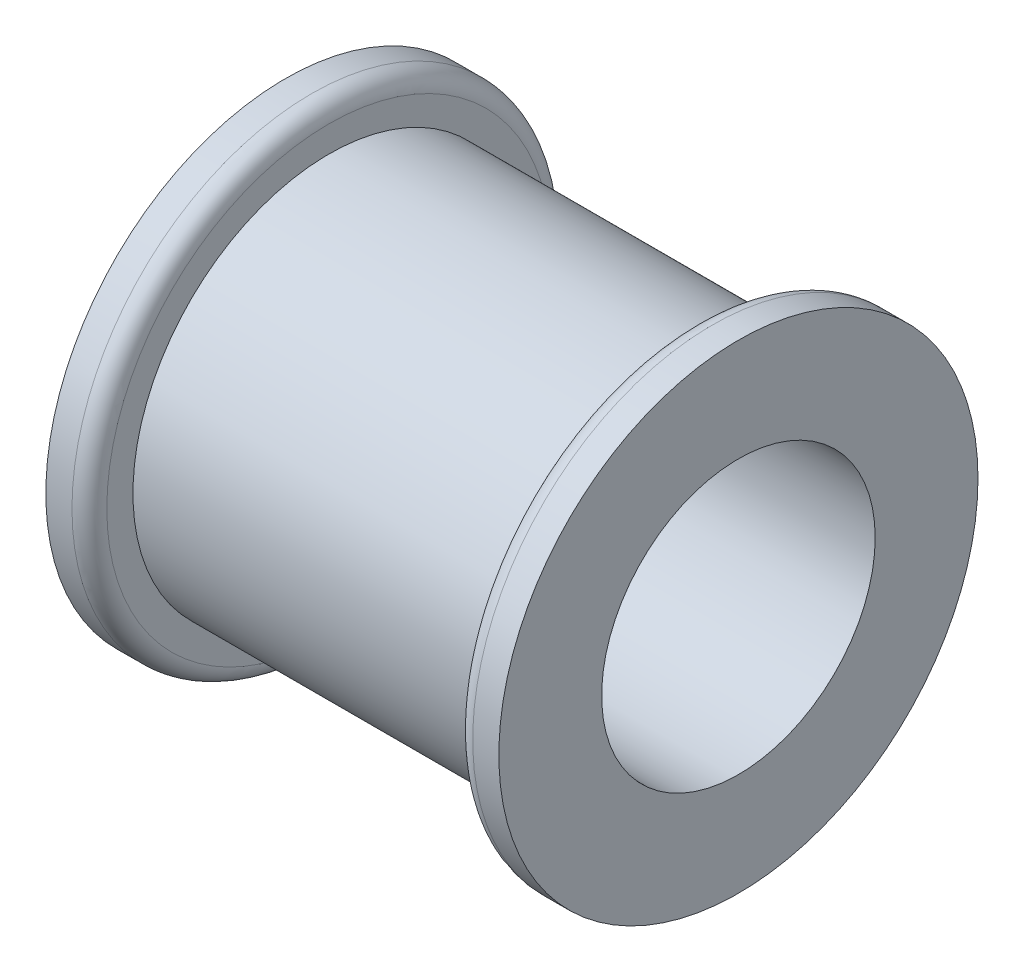
from build123d import *

# Parameters (mm, degrees)
SKETCH1_R            = 14.2875
SKETCH1_R_2          = 9.9695
BOSS_EXTRUDE1_DEPTH  = 26.67
SKETCH2_R            = 17.4625
SKETCH2_R_2          = 9.9695
BOSS_EXTRUDE2_DEPTH  = 3.175
FILLET1_R            = 1.27
FILLET1_OF_MIRROR1_R = 1.27


with BuildPart() as part:
    # Sketch1 → Boss-Extrude1 (new body)
    with BuildSketch(Plane(origin=(0, 0, 0), x_dir=(0, 0, -1), z_dir=(1, 0, 0))):
        Circle(SKETCH1_R)
        Circle(SKETCH1_R_2, mode=Mode.SUBTRACT)
    extrude(amount=BOSS_EXTRUDE1_DEPTH)

    # Sketch2 → Boss-Extrude2 (add)
    with BuildSketch(Plane(origin=(26.67, 0, 0), x_dir=(0, 0, -1), z_dir=(1, 0, 0))):
        Circle(SKETCH2_R)
        Circle(SKETCH2_R_2, mode=Mode.SUBTRACT)
    boss_extrude2 = extrude(amount=BOSS_EXTRUDE2_DEPTH)

    # Fillet1
    fillet1_edges = [part.edges().sort_by_distance(p)[0] for p in [
        (26.67, 0, 17.4625),
    ]]
    fillet(fillet1_edges, radius=FILLET1_R)

    # Mirror1: Boss-Extrude2 across plane
    add(boss_extrude2.mirror(Plane.ZY.offset(-13.335)))

    # Fillet1 of Mirror1
    fillet1_of_mirror1_edges = [part.edges().sort_by_distance(p)[0] for p in [
        (0, 0, 17.4625),
    ]]
    fillet(fillet1_of_mirror1_edges, radius=FILLET1_OF_MIRROR1_R)


solid = part.part
